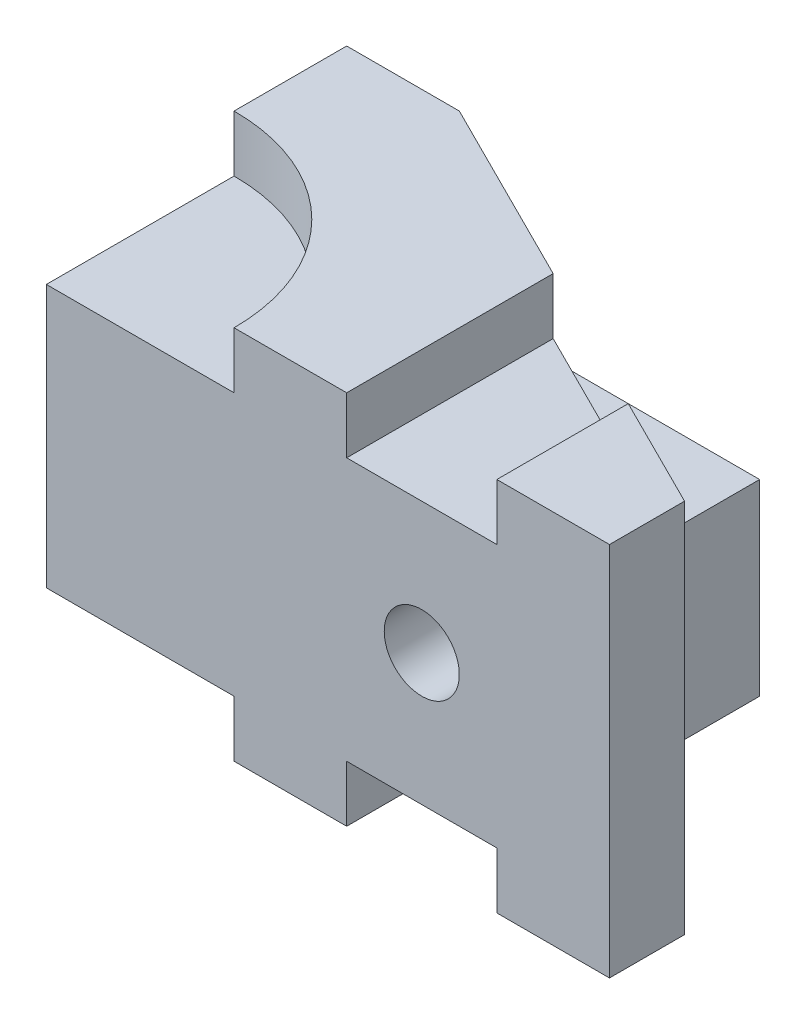
from build123d import *

# Parameters (mm, degrees)
BOSS_EXTRUDE1_DEPTH = 100
SKETCH2_R           = 50
CUT_EXTRUDE1_DEPTH  = 15
CUT_EXTRUDE2_DEPTH  = 25
SKETCH4_W           = 70
SKETCH4_H           = 30
CUT_EXTRUDE3_DEPTH  = 21
SKETCH5_R           = 10
CUT_EXTRUDE4_DEPTH  = 61


with BuildPart() as part:
    # Sketch1 → Boss-Extrude1 (new body)
    with BuildSketch(Plane(origin=(0, 0, 0), x_dir=(1, 0, 0), z_dir=(0, 1, 0))):
        Polygon((-5, 20), (-45, 40), (-75, 40), (-75, -40), (75, -40), (75, -20), (55, -10), (55, 20), align=None)
    extrude(amount=BOSS_EXTRUDE1_DEPTH)

    # Sketch2 → Cut-Extrude1 (cut)
    with BuildSketch(Plane(origin=(0, 100, 0), x_dir=(1, 0, 0), z_dir=(0, 1, 0))):
        with Locations((-75, -40)):
            Circle(SKETCH2_R)
        Polygon((5, -40), (5, 15), (45, -5), (45, -40), align=None)
    cut_extrude1 = extrude(amount=-CUT_EXTRUDE1_DEPTH, mode=Mode.SUBTRACT)

    # Sketch3 → Cut-Extrude2 (cut)
    with BuildSketch(Plane(origin=(0, 100, 0), x_dir=(1, 0, 0), z_dir=(0, 1, 0))):
        Polygon((-5, 20), (55, -10), (55, 20), align=None)
    cut_extrude2 = extrude(amount=-CUT_EXTRUDE2_DEPTH, mode=Mode.SUBTRACT)

    # Mirror1: Cut-Extrude1, Cut-Extrude2 across plane
    add(cut_extrude1.mirror(Plane.ZX.offset(50)), mode=Mode.SUBTRACT)
    add(cut_extrude2.mirror(Plane.ZX.offset(50)), mode=Mode.SUBTRACT)

    # Sketch4 → Cut-Extrude3 (cut, through all)
    with BuildSketch(Plane(origin=(0, 0, -20), x_dir=(-1, 0, 0), z_dir=(0, 0, -1))):
        with Locations((40, 50)):
            Rectangle(SKETCH4_W, SKETCH4_H)
    extrude(amount=CUT_EXTRUDE3_DEPTH, mode=Mode.SUBTRACT)

    # Sketch5 → Cut-Extrude4 (cut, through all)
    with BuildSketch(Plane(origin=(0, 0, -20), x_dir=(-1, 0, 0), z_dir=(0, 0, -1))):
        with Locations((-25, 50)):
            Circle(SKETCH5_R)
    extrude(amount=-CUT_EXTRUDE4_DEPTH, mode=Mode.SUBTRACT)


solid = part.part
